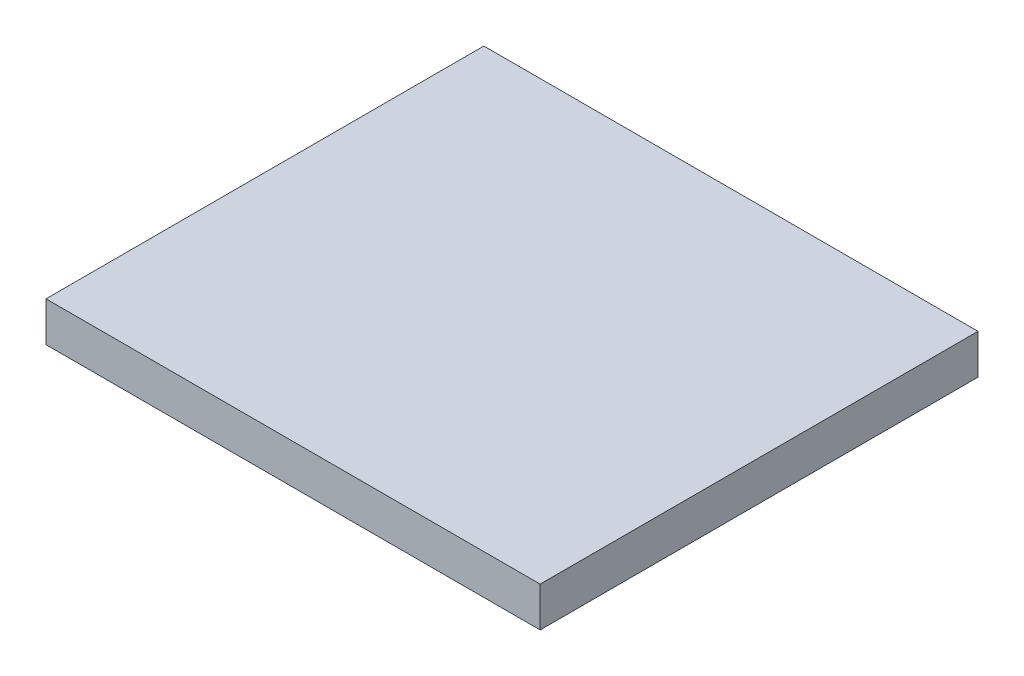
from build123d import *

# Parameters (mm, degrees)
SKETCH1_W           = 39.5
SKETCH1_H           = 35
BOSS_EXTRUDE1_DEPTH = 3.175


with BuildPart() as part:
    # Sketch1 → Boss-Extrude1 (new body)
    with BuildSketch(Plane(origin=(0, 0, 0), x_dir=(1, 0, 0), z_dir=(0, 1, 0))):
        with Locations((-23.812893726, -11.789094505)):
            Rectangle(SKETCH1_W, SKETCH1_H)
    extrude(amount=BOSS_EXTRUDE1_DEPTH)


solid = part.part
